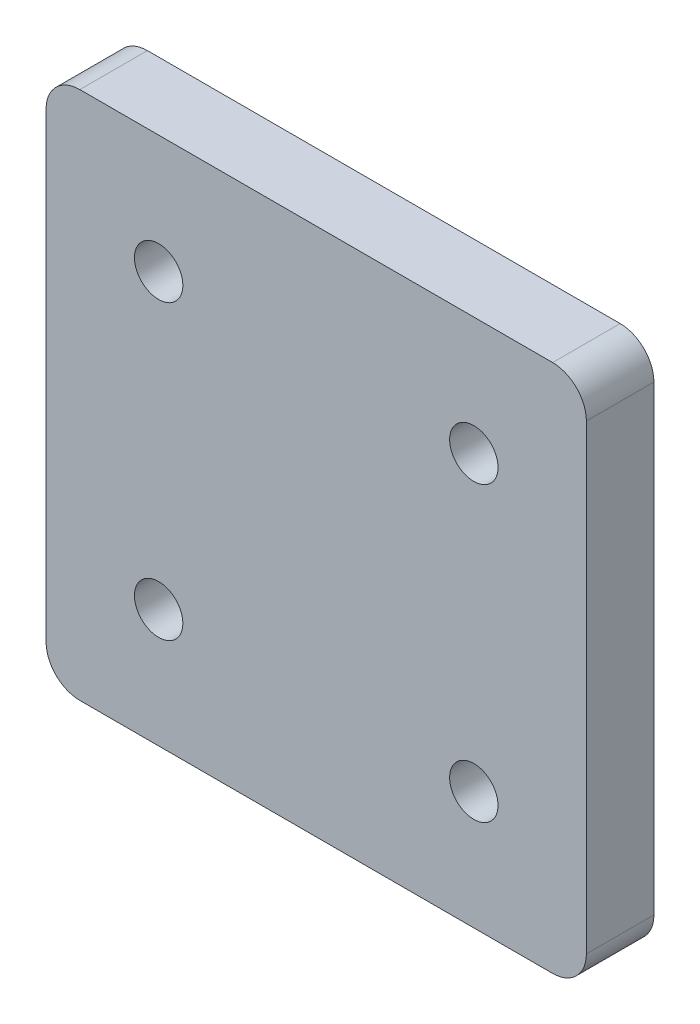
from build123d import *

# Parameters (mm, degrees)
SKETCH1_W           = 48
SKETCH1_H           = 47
SKETCH1_R           = 1.65
BOSS_EXTRUDE1_DEPTH = 6
SKETCH2_R           = 2.15
CUT_EXTRUDE1_DEPTH  = 7
FILLET1_R           = 3


with BuildPart() as part:
    # Sketch1 → Boss-Extrude1 (new body)
    with BuildSketch(Plane.XY):
        with Locations((0, -19.5)):
            Rectangle(SKETCH1_W, SKETCH1_H)
        with Locations((14, -32.5)):
            Circle(SKETCH1_R, mode=Mode.SUBTRACT)
        with Locations((-14, -32.5)):
            Circle(SKETCH1_R, mode=Mode.SUBTRACT)
        with Locations((-14, -6.5)):
            Circle(SKETCH1_R, mode=Mode.SUBTRACT)
        with Locations((14, -6.5)):
            Circle(SKETCH1_R, mode=Mode.SUBTRACT)
    extrude(amount=BOSS_EXTRUDE1_DEPTH)

    # Sketch2 → Cut-Extrude1 (cut, through all)
    with BuildSketch(Plane.XY.offset(6)):
        with Locations((-14, -6.5)):
            Circle(SKETCH2_R)
        with Locations((14, -6.5)):
            Circle(SKETCH2_R)
        with Locations((-14, -32.5)):
            Circle(SKETCH2_R)
        with Locations((14, -32.5)):
            Circle(SKETCH2_R)
    extrude(amount=-CUT_EXTRUDE1_DEPTH, mode=Mode.SUBTRACT)

    # Fillet1
    fillet1_edges = [part.edges().sort_by_distance(p)[0] for p in [
        (24, -43, 3),
        (-24, -43, 3),
        (-24, 4, 3),
        (24, 4, 3),
    ]]
    fillet(fillet1_edges, radius=FILLET1_R)


solid = part.part
